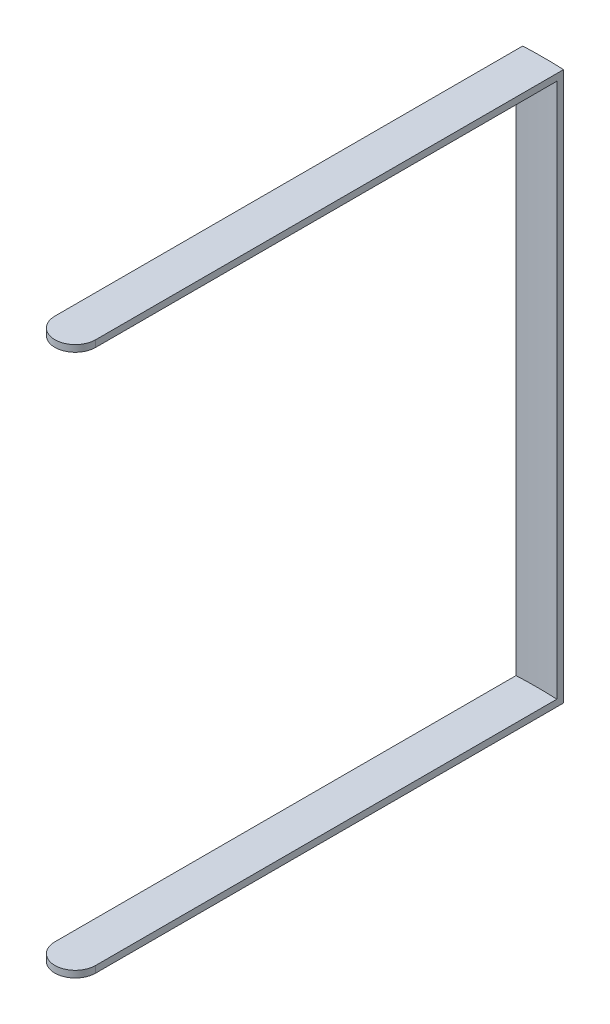
from build123d import *

# Parameters (mm, degrees)
BOSS_EXTRUDE1_DEPTH = 2.54
BOSS_EXTRUDE2_DEPTH = 203.2
BOSS_EXTRUDE3_DEPTH = 2.54


with BuildPart() as part:
    # Sketch1 → Boss-Extrude1 (new body)
    with BuildSketch(Plane(origin=(0, 0, 0), x_dir=(1, 0, 0), z_dir=(0, 1, 0))):
        with BuildLine():
            Line((-7.755527074, 0), (-7.755527074, 177.630773797))
            ThreePointArc((-7.755527074, 177.630773797), (0, 177.8), (7.755527074, 177.630773797))
            Line((7.755527074, 177.630773797), (7.755527074, 0))
            ThreePointArc((7.755527074, 0), (0, -7.755527074), (-7.755527074, 0))
        make_face()
    extrude(amount=BOSS_EXTRUDE1_DEPTH)

    # Sketch2 → Boss-Extrude2 (add)
    with BuildSketch(Plane(origin=(0, 2.54, 0), x_dir=(1, 0, 0), z_dir=(0, 1, 0))):
        with BuildLine():
            Line((-7.755527074, 177.630773797), (-7.755527074, 175.090773797))
            ThreePointArc((-7.755527074, 175.090773797), (0, 175.262452537), (7.755527074, 175.090773797))
            Line((7.755527074, 175.090773797), (7.755527074, 177.630773797))
            ThreePointArc((7.755527074, 177.630773797), (0, 177.8), (-7.755527074, 177.630773797))
        make_face()
    extrude(amount=BOSS_EXTRUDE2_DEPTH)

    # Sketch3 → Boss-Extrude3 (add)
    with BuildSketch(Plane(origin=(0, 205.74, 0), x_dir=(1, 0, 0), z_dir=(0, 1, 0))):
        with BuildLine():
            Line((-7.755527074, 0), (-7.755527074, 177.630773797))
            ThreePointArc((-7.755527074, 177.630773797), (0, 177.8), (7.755527074, 177.630773797))
            Line((7.755527074, 177.630773797), (7.755527074, 0))
            ThreePointArc((7.755527074, 0), (0, -7.755527074), (-7.755527074, 0))
        make_face()
    extrude(amount=BOSS_EXTRUDE3_DEPTH)


solid = part.part
